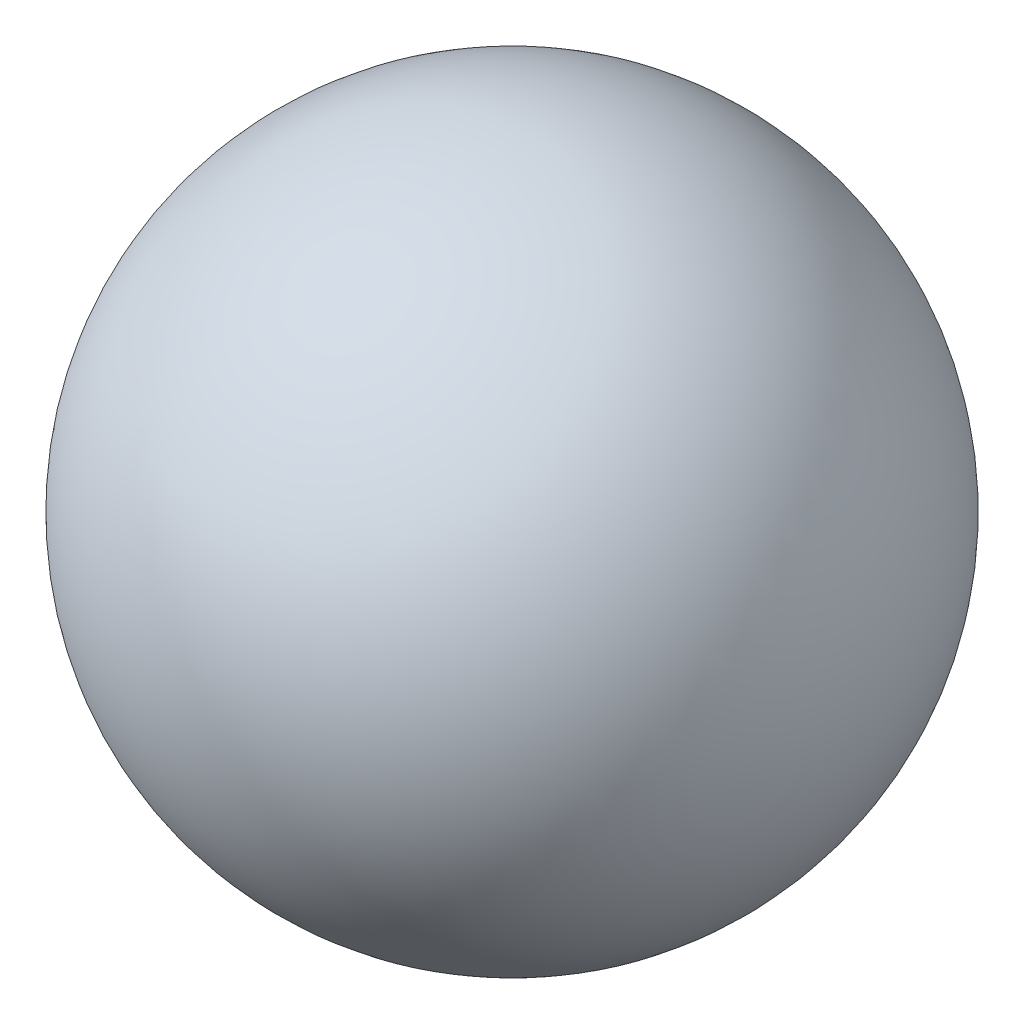
from build123d import *


with BuildPart() as part:
    # Sketch1 → Revolve1 (revolve)
    with BuildSketch(Plane.XY):
        with BuildLine():
            Line((0, 1), (0, -1))
            ThreePointArc((0, -1), (-1, 0), (0, 1))
        make_face()
    revolve(axis=Axis((0, 1, 0), (0, -1, 0)))


solid = part.part
